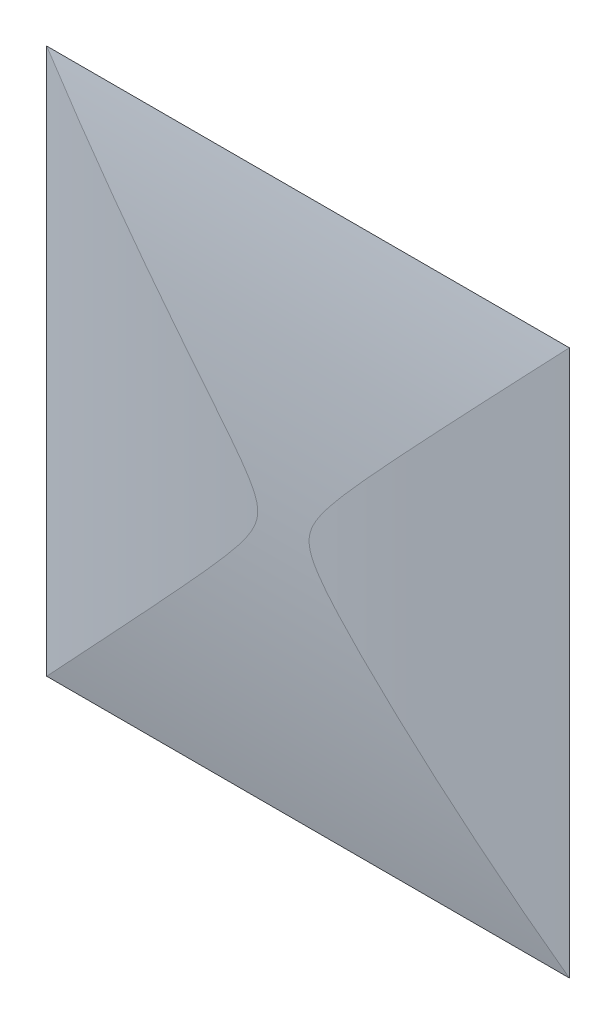
from build123d import *

# Parameters (mm, degrees)
SKETCH1_W                  = 11.3
SKETCH1_H                  = 11.8
KEY_DEPTH                  = 1
EXTRUDE2_DEPTH             = 12.8
CORTAR_EXTRUIR2_DEPTH      = 6.65
CORTAR_EXTRUIR2_DEPTH_BACK = 6.65


with BuildPart() as part:
    # Sketch1 → key (new body)
    with BuildSketch(Plane.XY):
        Rectangle(SKETCH1_W, SKETCH1_H)
    extrude(amount=KEY_DEPTH)

    # Sketch2 → Extrude2 (cut, through all)
    with BuildSketch(Plane.XZ.offset(5.9)):
        with BuildLine():
            Line((-5.65, 0), (-5.65, 1))
            Line((-5.65, 1), (5.65, 1))
            Line((5.65, 1), (5.65, 0))
            ThreePointArc((5.65, 0), (0, 0.536845043), (-5.65, 0))
        make_face()
    extrude(amount=-EXTRUDE2_DEPTH, mode=Mode.SUBTRACT)

    # Croquis1 → Cortar-Extruir2 (cut, two sides)
    with BuildSketch(Plane(origin=(0, 0, 0), x_dir=(0, 0, -1), z_dir=(1, 0, 0))) as cortar_extruir2_sk:
        with BuildLine():
            Line((0, 5.9), (-1.525972396, 5.9))
            Line((-1.525972396, 5.9), (-1.525972396, -5.9))
            Line((-1.525972396, -5.9), (0, -5.9))
            ThreePointArc((0, -5.9), (-0.531707775, 0), (0, 5.9))
        make_face()
    extrude(amount=CORTAR_EXTRUIR2_DEPTH, mode=Mode.SUBTRACT)
    extrude(cortar_extruir2_sk.sketch, amount=-CORTAR_EXTRUIR2_DEPTH_BACK, mode=Mode.SUBTRACT)


solid = part.part
